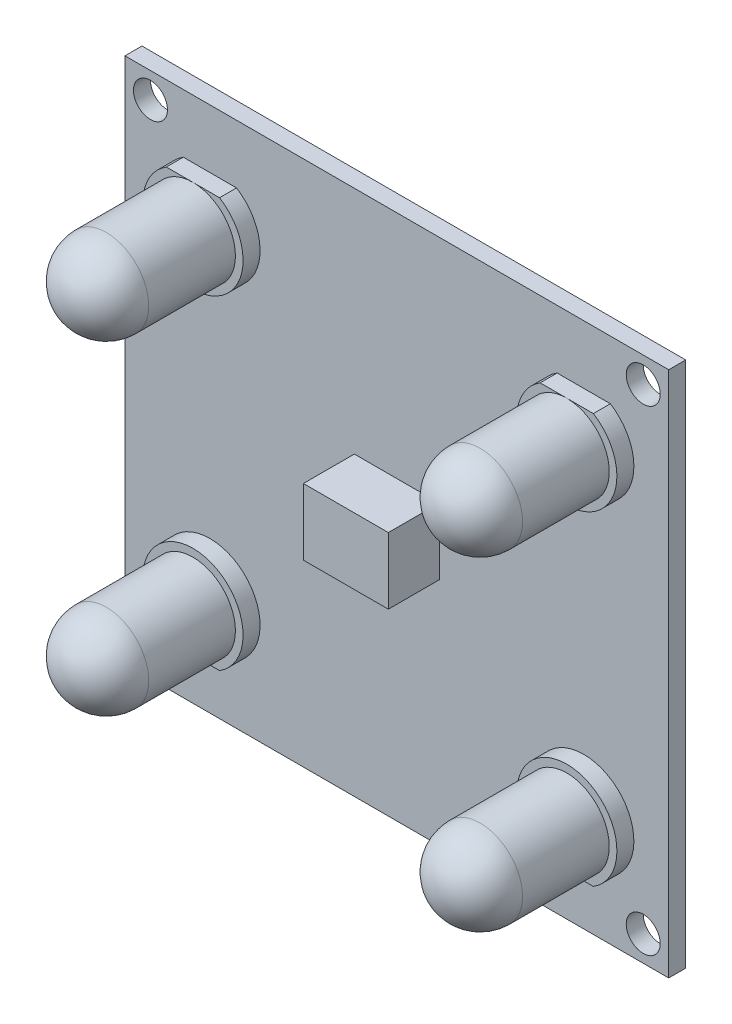
from build123d import *

# Parameters (mm, degrees)
SKETCH1_W             = 32
SKETCH1_H             = 25
BOSS_EXTRUDE1_DEPTH   = 1
SKETCH2_R             = 2.5
SKETCH2_W             = 5
SKETCH2_H             = 4.545454546
BOSS_EXTRUDE2_DEPTH   = 8.7
SKETCH3_W             = 7.112296494
SKETCH3_H             = 6.624197715
CUT_EXTRUDE1_DEPTH    = 5.7
FILLET3_R             = 0.5
FILLET4_R             = 2.5
FILLET5_R             = 2.5
SKETCH4_R             = 2.5
CUT_EXTRUDE2_DEPTH    = 10
SKETCH5_R             = 2.95
BOSS_EXTRUDE3_DEPTH   = 1
BOSS_EXTRUDE3_2_DEPTH = 1
BOSS_EXTRUDE3_3_DEPTH = 1
BOSS_EXTRUDE3_4_DEPTH = 1
SKETCH8_R             = 2.5
BOSS_EXTRUDE6_DEPTH   = 7.6
CUT_EXTRUDE4_DEPTH    = 1
FILLET6_R             = 2.5
SKETCH13_R            = 2.367564394
BOSS_EXTRUDE7_DEPTH   = 7.6
SKETCH13_R_2          = 2.5
BOSS_EXTRUDE7_2_DEPTH = 7.6
BOSS_EXTRUDE7_3_DEPTH = 7.6
FILLET7_R             = 2.5
FILLET10_R            = 2.5
SKETCH14_R            = 2.367564394
CUT_EXTRUDE6_DEPTH    = 7.6
SKETCH15_R            = 2.5
BOSS_EXTRUDE9_DEPTH   = 7.6
FILLET12_R            = 2.5
SKETCH16_W            = 25.26079324
SKETCH16_H            = 1.326651886
CUT_EXTRUDE7_DEPTH    = 1
SKETCH17_W            = 30.705826602
SKETCH17_H            = 1.654596323
CUT_EXTRUDE8_DEPTH    = 1
SKETCH21_W            = 5
SKETCH21_H            = 4.545454546
CUT_EXTRUDE10_DEPTH   = 3
SKETCH22_W            = 5
SKETCH22_H            = 3.90625
BOSS_EXTRUDE11_DEPTH  = 3
SKETCH24_W            = 32
SKETCH24_H            = 1
BOSS_EXTRUDE16_DEPTH  = 3
SKETCH26_W            = 32
SKETCH26_H            = 1
BOSS_EXTRUDE17_DEPTH  = 3
SKETCH27_R            = 1
CUT_EXTRUDE11_DEPTH   = 3


with BuildPart() as part:
    # Sketch1 → Boss-Extrude1 (new body)
    with BuildSketch(Plane.XY):
        with Locations((-6.125714286, 5.877142857)):
            Rectangle(SKETCH1_W, SKETCH1_H)
    extrude(amount=BOSS_EXTRUDE1_DEPTH)

    # Sketch2 → Boss-Extrude2 (add)
    with BuildSketch(Plane.XY.offset(1)):
        with Locations((-17.125714286, 15.877142857)):
            Circle(SKETCH2_R)
        with Locations((4.874285714, 15.877142857)):
            Circle(SKETCH2_R)
        with Locations((-17.125714286, -4.122857143)):
            Circle(SKETCH2_R)
        with Locations((4.874285714, -4.122857143)):
            Circle(SKETCH2_R)
        with Locations((-6.125714286, 5.877142857)):
            Rectangle(SKETCH2_W, SKETCH2_H)
    extrude(amount=BOSS_EXTRUDE2_DEPTH)

    # Sketch3 → Cut-Extrude1 (cut)
    with BuildSketch(Plane.XY.offset(9.7)):
        with Locations((-6.125714286, 5.859710758)):
            Rectangle(SKETCH3_W, SKETCH3_H)
    extrude(amount=-CUT_EXTRUDE1_DEPTH, mode=Mode.SUBTRACT)

    # Fillet3
    fillet3_edges = [part.edges().sort_by_distance(p)[0] for p in [
        (-6.125714286, 3.604415584, 4),
        (-3.625714286, 5.877142857, 4),
        (-6.125714286, 8.14987013, 4),
        (-8.625714286, 5.877142857, 4),
    ]]
    fillet(fillet3_edges, radius=FILLET3_R)

    # Fillet4
    fillet4_edges = [part.edges().sort_by_distance(p)[0] for p in [
        (2.374285714, 15.877142857, 9.7),
    ]]
    fillet(fillet4_edges, radius=FILLET4_R)

    # Fillet5
    fillet5_edges = [part.edges().sort_by_distance(p)[0] for p in [
        (-19.625714286, 15.877142857, 9.7),
        (-19.625714286, -4.122857143, 9.7),
        (2.374285714, -4.122857143, 9.7),
    ]]
    fillet(fillet5_edges, radius=FILLET5_R)

    # Sketch4 → Cut-Extrude2 (cut)
    with BuildSketch(Plane.XY.offset(1)):
        with Locations((-17.125714286, -4.122857143)):
            Circle(SKETCH4_R)
        with Locations((-17.125714286, 15.877142857)):
            Circle(SKETCH4_R)
        with Locations((4.874285714, 15.877142857)):
            Circle(SKETCH4_R)
        with Locations((4.874285714, -4.122857143)):
            Circle(SKETCH4_R)
    extrude(amount=CUT_EXTRUDE2_DEPTH, mode=Mode.SUBTRACT)

    # Sketch21 → Cut-Extrude10 (cut)
    with BuildSketch(Plane.XY.offset(4)):
        with Locations((-6.125714286, 5.877142857)):
            Rectangle(SKETCH21_W, SKETCH21_H)
    extrude(amount=-CUT_EXTRUDE10_DEPTH, mode=Mode.SUBTRACT)

    # Sketch24 → Boss-Extrude16 (add)
    with BuildSketch(Plane(origin=(0, 18.377142857, 0), x_dir=(1, 0, 0), z_dir=(0, 1, 0))):
        with Locations((-6.125714286, -0.5)):
            Rectangle(SKETCH24_W, SKETCH24_H)
    extrude(amount=BOSS_EXTRUDE16_DEPTH)

    # Sketch26 → Boss-Extrude17 (add)
    with BuildSketch(Plane.XZ.offset(6.622857143)):
        with Locations((-6.125714286, 0.5)):
            Rectangle(SKETCH26_W, SKETCH26_H)
    extrude(amount=BOSS_EXTRUDE17_DEPTH)

    # Sketch27 → Cut-Extrude11 (cut)
    with BuildSketch(Plane(origin=(0, 0, 0), x_dir=(-1, 0, 0), z_dir=(0, 0, -1))):
        with Locations((-8.374285714, 19.877142857)):
            Circle(SKETCH27_R)
        with Locations((-8.374285714, -8.122857143)):
            Circle(SKETCH27_R)
        with Locations((20.625714286, -8.122857143)):
            Circle(SKETCH27_R)
        with Locations((20.625714286, 19.877142857)):
            Circle(SKETCH27_R)
    extrude(amount=-CUT_EXTRUDE11_DEPTH, mode=Mode.SUBTRACT)


with BuildPart() as body_2:
    # Sketch5 → Boss-Extrude3 (new body)
    with BuildSketch(Plane.XY.offset(1)):
        with Locations((-17.125714286, 15.427142857)):
            Circle(SKETCH5_R)
    extrude(amount=BOSS_EXTRUDE3_DEPTH)

    # Sketch9 → Cut-Extrude4 (cut)
    with BuildSketch(Plane.XY.offset(2)):
        Polygon((-17.125714286, 17.927142857), (-15.287192107, 17.927142857), (-15.485453781, 18.648454573), (-19.121317055, 18.622872422), (-19.121317055, 17.927142857), align=None)
    extrude(amount=-CUT_EXTRUDE4_DEPTH, mode=Mode.SUBTRACT)


with BuildPart() as body_3:
    # Sketch5 → Boss-Extrude3 2 (new body)
    with BuildSketch(Plane.XY.offset(1)):
        with Locations((-17.125714286, -3.672857143)):
            Circle(SKETCH5_R)
    extrude(amount=BOSS_EXTRUDE3_2_DEPTH)


with BuildPart() as body_4:
    # Sketch5 → Boss-Extrude3 3 (new body)
    with BuildSketch(Plane.XY.offset(1)):
        with Locations((4.874285714, 15.427142857)):
            Circle(SKETCH5_R)
    extrude(amount=BOSS_EXTRUDE3_3_DEPTH)

    # Sketch16 → Cut-Extrude7 (cut)
    with BuildSketch(Plane.XY.offset(2)):
        with Locations((-2.929271689, 18.5904688)):
            Rectangle(SKETCH16_W, SKETCH16_H)
    extrude(amount=-CUT_EXTRUDE7_DEPTH, mode=Mode.SUBTRACT)


with BuildPart() as body_5:
    # Sketch5 → Boss-Extrude3 4 (new body)
    with BuildSketch(Plane.XY.offset(1)):
        with Locations((4.874285714, -3.672857143)):
            Circle(SKETCH5_R)
    extrude(amount=BOSS_EXTRUDE3_4_DEPTH)


with BuildPart() as body_6:
    # Sketch8 → Boss-Extrude6 (new body)
    with BuildSketch(Plane.XY.offset(2)):
        with Locations((-17.125714286, 15.427142857)):
            Circle(SKETCH8_R)
    extrude(amount=BOSS_EXTRUDE6_DEPTH)

    # Fillet6
    fillet6_edges = [body_6.edges().sort_by_distance(p)[0] for p in [
        (-19.625714286, 15.427142857, 9.6),
    ]]
    fillet(fillet6_edges, radius=FILLET6_R)


with BuildPart() as body_7:
    # Sketch13 → Boss-Extrude7 (new body)
    with BuildSketch(Plane.XY.offset(2)):
        with Locations((4.874285714, 15.427142857)):
            Circle(SKETCH13_R)
    extrude(amount=BOSS_EXTRUDE7_DEPTH)

    # Sketch14 → Cut-Extrude6 (cut)
    with BuildSketch(Plane.XY.offset(9.6)):
        with Locations((4.874285714, 15.427142857)):
            Circle(SKETCH14_R)
    extrude(amount=-CUT_EXTRUDE6_DEPTH, mode=Mode.SUBTRACT)


with BuildPart() as body_8:
    # Sketch13 → Boss-Extrude7 2 (new body)
    with BuildSketch(Plane.XY.offset(2)):
        with Locations((-17.125714286, -3.672857143)):
            Circle(SKETCH13_R_2)
    extrude(amount=BOSS_EXTRUDE7_2_DEPTH)

    # Fillet7
    fillet7_edges = [body_8.edges().sort_by_distance(p)[0] for p in [
        (-19.625714286, -3.672857143, 9.6),
    ]]
    fillet(fillet7_edges, radius=FILLET7_R)


with BuildPart() as body_9:
    # Sketch13 → Boss-Extrude7 3 (new body)
    with BuildSketch(Plane.XY.offset(2)):
        with Locations((4.874285714, -3.672857143)):
            Circle(SKETCH13_R_2)
    extrude(amount=BOSS_EXTRUDE7_3_DEPTH)

    # Fillet10
    fillet10_edges = [body_9.edges().sort_by_distance(p)[0] for p in [
        (2.374285714, -3.672857143, 9.6),
    ]]
    fillet(fillet10_edges, radius=FILLET10_R)


with BuildPart() as body_9_2:
    # Sketch15 → Boss-Extrude9 (new body)
    with BuildSketch(Plane.XY.offset(2)):
        with Locations((4.874285714, 15.427142857)):
            Circle(SKETCH15_R)
    extrude(amount=BOSS_EXTRUDE9_DEPTH)

    # Fillet12
    fillet12_edges = [body_9_2.edges().sort_by_distance(p)[0] for p in [
        (2.374285714, 15.427142857, 9.6),
    ]]
    fillet(fillet12_edges, radius=FILLET12_R)


with BuildPart() as cut_extrude8_tool:
    # Sketch17 → Cut-Extrude8 (new body)
    with BuildSketch(Plane.XY.offset(2)):
        with Locations((-6.180226628, -7.000761591)):
            Rectangle(SKETCH17_W, SKETCH17_H)
    extrude(amount=-CUT_EXTRUDE8_DEPTH)


with BuildPart() as body_3_1:
    add(body_3.part)

    # Cut-Extrude8: cut by cut_extrude8_tool
    add(cut_extrude8_tool.part, mode=Mode.SUBTRACT)


with BuildPart() as body_5_1:
    add(body_5.part)

    # Cut-Extrude8: cut by cut_extrude8_tool
    add(cut_extrude8_tool.part, mode=Mode.SUBTRACT)


with BuildPart() as body_10:
    # Sketch22 → Boss-Extrude11 (new body)
    with BuildSketch(Plane.XY.offset(1)):
        with Locations((-6.125714286, 5.877142857)):
            Rectangle(SKETCH22_W, SKETCH22_H)
    extrude(amount=BOSS_EXTRUDE11_DEPTH)


solid = Compound([part.part, body_2.part, body_4.part, body_6.part, body_8.part, body_9.part, body_9_2.part, body_3_1.part, body_5_1.part, body_10.part])
